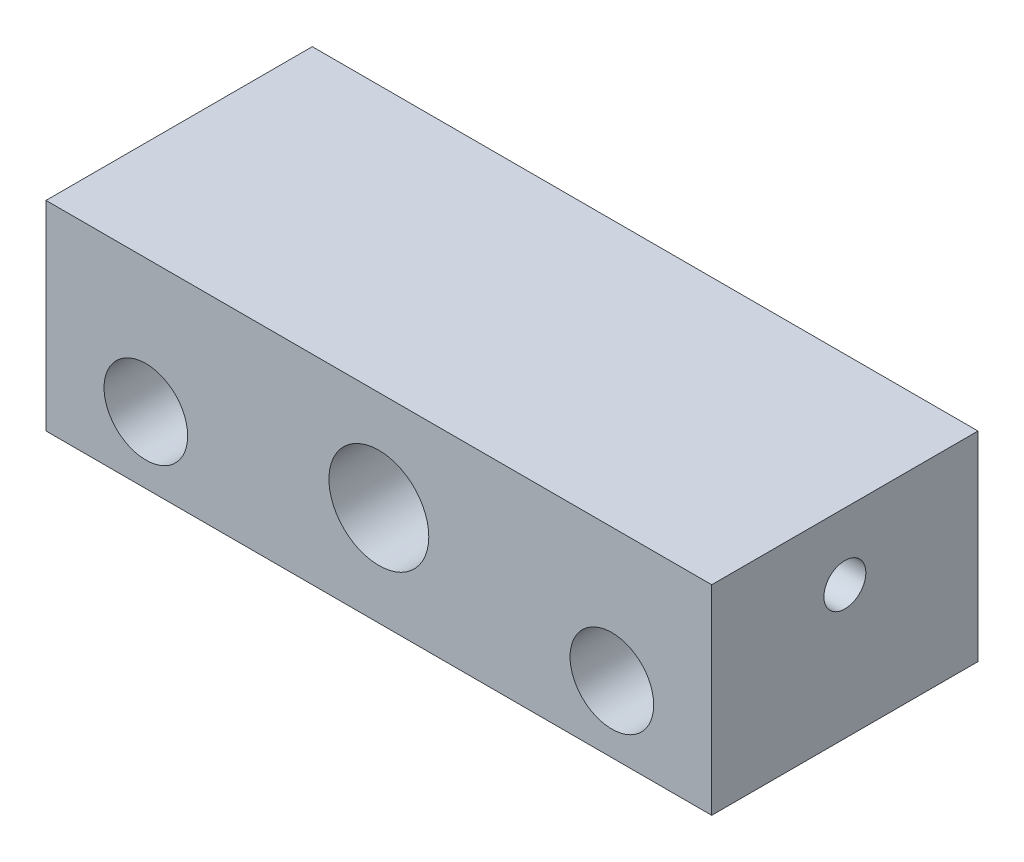
from build123d import *

# Parameters (mm, degrees)
SKETCH1_W           = 63.5
SKETCH1_H           = 19.05
SKETCH1_R           = 4.7625
SKETCH1_R_2         = 3.9878
BOSS_EXTRUDE1_DEPTH = 25.4
SKETCH2_R           = 2
CUT_EXTRUDE1_DEPTH  = 6.35


with BuildPart() as part:
    # Sketch1 → Boss-Extrude1 (new body)
    with BuildSketch(Plane.XY):
        Rectangle(SKETCH1_W, SKETCH1_H)
        Circle(SKETCH1_R, mode=Mode.SUBTRACT)
        with Locations((-22.225, -3.175)):
            Circle(SKETCH1_R_2, mode=Mode.SUBTRACT)
        with Locations((22.225, -3.175)):
            Circle(SKETCH1_R_2, mode=Mode.SUBTRACT)
    extrude(amount=-BOSS_EXTRUDE1_DEPTH)

    # Sketch2 → Cut-Extrude1 (cut)
    with BuildSketch(Plane.ZY.offset(31.75)):
        with Locations((-12.7, 3.175)):
            Circle(SKETCH2_R)
    cut_extrude1 = extrude(amount=-CUT_EXTRUDE1_DEPTH, mode=Mode.SUBTRACT)

    # Mirror1: Cut-Extrude1 across plane
    add(cut_extrude1.mirror(Plane.ZY), mode=Mode.SUBTRACT)


solid = part.part
